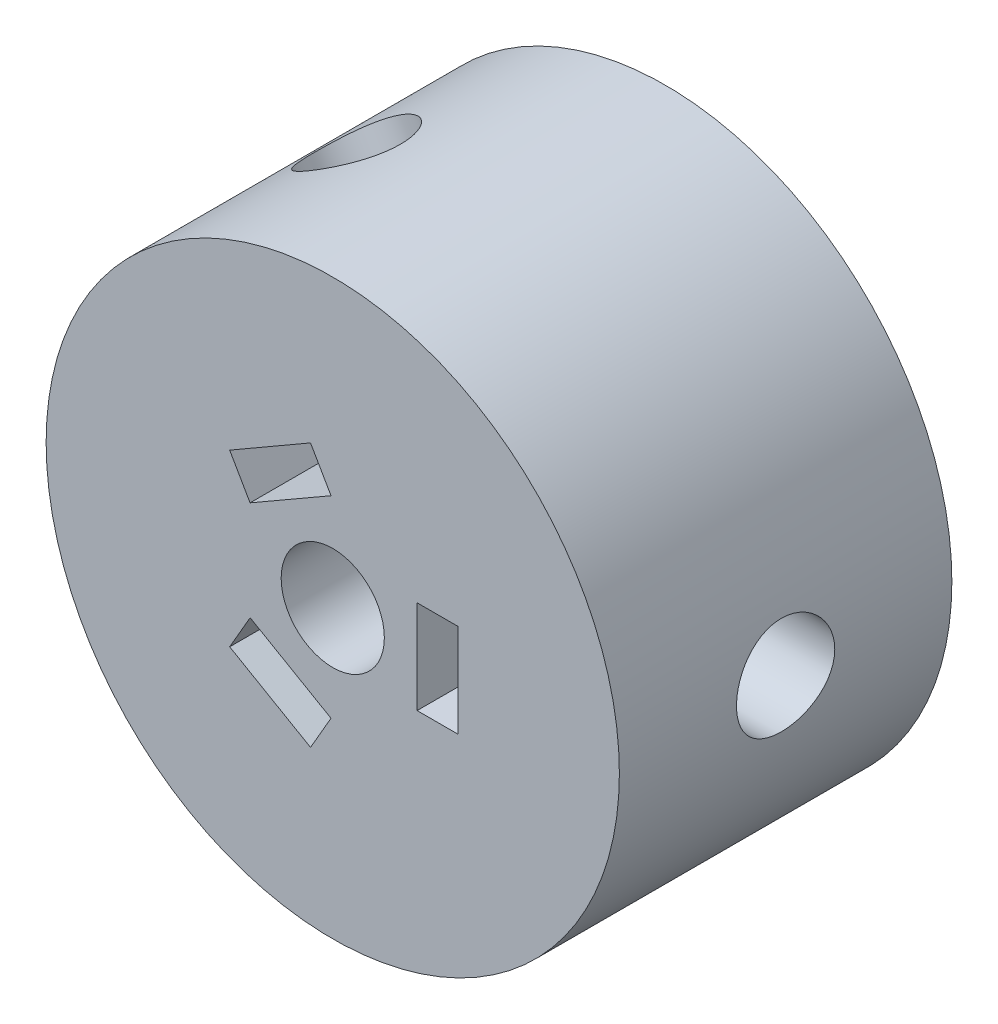
from build123d import *

# Parameters (mm, degrees)
SKETCH1_R           = 17.5
SKETCH1_R_2         = 3.15
BOSS_EXTRUDE1_DEPTH = 40.3
CUT_EXTRUDE1_DEPTH  = 23
CUT_EXTRUDE4_REACH  = 43.405
SKETCH8_R           = 1.65
CUT_EXTRUDE5_REACH  = 43.405
SKETCH10_R          = 1.65
SKETCH12_R          = 3
CUT_EXTRUDE6_DEPTH  = 5.35
SKETCH15_R          = 3
CUT_EXTRUDE8_DEPTH  = 5.35
CUT_EXTRUDE9_REACH  = 43.405
SKETCH17_R          = 1.65
CUT_EXTRUDE10_REACH = 43.405
SKETCH18_R          = 1.65
SKETCH19_R          = 3
CUT_EXTRUDE11_DEPTH = 5.35
CUT_EXTRUDE12_REACH = 37
SKETCH20_R          = 1.65
CUT_EXTRUDE13_REACH = 37
SKETCH21_R          = 1.65
SKETCH22_R          = 17.5
CUT_EXTRUDE14_DEPTH = 10
SKETCH23_R          = 17.5
CUT_EXTRUDE15_DEPTH = 10


with BuildPart() as part:
    # Sketch1 → Boss-Extrude1 (new body)
    with BuildSketch(Plane.XY):
        Circle(SKETCH1_R)
        Circle(SKETCH1_R_2, mode=Mode.SUBTRACT)
    extrude(amount=BOSS_EXTRUDE1_DEPTH)

    # Sketch2 → Cut-Extrude1 (cut)
    with BuildSketch(Plane.XY.offset(40.3)):
        Polygon((7.65, 0), (7.65, 2.85), (5.15, 2.85), (5.15, -2.85), (7.65, -2.85), align=None)
        Polygon((-3.825, -6.625094339), (-1.356827599, -8.050094339), (-0.106827599, -5.885030829), (-5.043172401, -3.035030829), (-6.293172401, -5.200094339), align=None)
        Polygon((-3.825, 6.625094339), (-6.293172401, 5.200094339), (-5.048242412, 3.035349353), (-0.105426694, 5.882604512), (-1.356827546, 8.050094369), align=None)
    extrude(amount=-CUT_EXTRUDE1_DEPTH, mode=Mode.SUBTRACT)

    # Sketch8 → Cut-Extrude4 (cut, up to next)
    with BuildSketch(Plane(origin=(-8.75, -15.155444566, 0), x_dir=(0, 0, -1), z_dir=(-0.5, -0.866025404, 0)), mode=Mode.PRIVATE) as cut_extrude4_sk1:
        with Locations((-20.15, 0)):
            Circle(SKETCH8_R)
    cut_extrude4_tool1 = extrude(cut_extrude4_sk1.sketch, amount=-CUT_EXTRUDE4_REACH, mode=Mode.PRIVATE) & part.part
    add(cut_extrude4_tool1.solids().sort_by_distance((-8.75, -15.155445, 20.15))[0], mode=Mode.SUBTRACT)

    # Sketch10 → Cut-Extrude5 (cut, up to next)
    with BuildSketch(Plane(origin=(-8.75, -15.155444566, 0), x_dir=(0, 0, -1), z_dir=(-0.5, -0.866025404, 0)), mode=Mode.PRIVATE) as cut_extrude5_sk1:
        with Locations((-20.15, 0)):
            Circle(SKETCH10_R)
    cut_extrude5_tool1 = extrude(cut_extrude5_sk1.sketch, amount=-CUT_EXTRUDE5_REACH, mode=Mode.PRIVATE) & part.part
    add(cut_extrude5_tool1.solids().sort_by_distance((-8.75, -15.155445, 20.15))[0], mode=Mode.SUBTRACT)

    # Sketch12 → Cut-Extrude6 (cut)
    with BuildSketch(Plane(origin=(-8.75, -15.155444566, 0), x_dir=(0, 0, -1), z_dir=(-0.5, -0.866025404, 0))):
        with Locations((-20.15, 0)):
            Circle(SKETCH12_R)
    extrude(amount=-CUT_EXTRUDE6_DEPTH, mode=Mode.SUBTRACT)

    # Sketch15 → Cut-Extrude8 (cut)
    with BuildSketch(Plane(origin=(-8.75, 15.155444566, 0), x_dir=(0, 0, -1), z_dir=(-0.5, 0.866025404, 0))):
        with Locations((-20.15, 0)):
            Circle(SKETCH15_R)
    extrude(amount=-CUT_EXTRUDE8_DEPTH, mode=Mode.SUBTRACT)

    # Sketch17 → Cut-Extrude9 (cut, up to next)
    with BuildSketch(Plane(origin=(-8.75, 15.155444566, 0), x_dir=(0, 0, -1), z_dir=(-0.5, 0.866025404, 0)), mode=Mode.PRIVATE) as cut_extrude9_sk1:
        with Locations((-20.15, 0)):
            Circle(SKETCH17_R)
    cut_extrude9_tool1 = extrude(cut_extrude9_sk1.sketch, amount=-CUT_EXTRUDE9_REACH, mode=Mode.PRIVATE) & part.part
    add(cut_extrude9_tool1.solids().sort_by_distance((-8.75, 15.155445, 20.15))[0], mode=Mode.SUBTRACT)

    # Sketch18 → Cut-Extrude10 (cut, up to next)
    with BuildSketch(Plane(origin=(-8.75, 15.155444566, 0), x_dir=(0, 0, -1), z_dir=(-0.5, 0.866025404, 0)), mode=Mode.PRIVATE) as cut_extrude10_sk1:
        with Locations((-20.15, 0)):
            Circle(SKETCH18_R)
    cut_extrude10_tool1 = extrude(cut_extrude10_sk1.sketch, amount=-CUT_EXTRUDE10_REACH, mode=Mode.PRIVATE) & part.part
    add(cut_extrude10_tool1.solids().sort_by_distance((-8.75, 15.155445, 20.15))[0], mode=Mode.SUBTRACT)

    # Sketch19 → Cut-Extrude11 (cut)
    with BuildSketch(Plane(origin=(17.5, 0, 0), x_dir=(0, 0, -1), z_dir=(1, 0, 0))):
        with Locations((-20.15, 0)):
            Circle(SKETCH19_R)
    extrude(amount=-CUT_EXTRUDE11_DEPTH, mode=Mode.SUBTRACT)

    # Sketch20 → Cut-Extrude12 (cut, up to next)
    with BuildSketch(Plane(origin=(17.5, 0, 0), x_dir=(0, 0, -1), z_dir=(1, 0, 0)), mode=Mode.PRIVATE) as cut_extrude12_sk1:
        with Locations((-20.15, 0)):
            Circle(SKETCH20_R)
    cut_extrude12_tool1 = extrude(cut_extrude12_sk1.sketch, amount=-CUT_EXTRUDE12_REACH, mode=Mode.PRIVATE) & part.part
    add(cut_extrude12_tool1.solids().sort_by_distance((17.5, 0, 20.15))[0], mode=Mode.SUBTRACT)

    # Sketch21 → Cut-Extrude13 (cut, up to next)
    with BuildSketch(Plane(origin=(17.5, 0, 0), x_dir=(0, 0, -1), z_dir=(1, 0, 0)), mode=Mode.PRIVATE) as cut_extrude13_sk1:
        with Locations((-20.15, 0)):
            Circle(SKETCH21_R)
    cut_extrude13_tool1 = extrude(cut_extrude13_sk1.sketch, amount=-CUT_EXTRUDE13_REACH, mode=Mode.PRIVATE) & part.part
    add(cut_extrude13_tool1.solids().sort_by_distance((17.5, 0, 20.15))[0], mode=Mode.SUBTRACT)

    # Sketch22 → Cut-Extrude14 (cut)
    with BuildSketch(Plane(origin=(0, 0, 0), x_dir=(-1, 0, 0), z_dir=(0, 0, -1))):
        Circle(SKETCH22_R)
    extrude(amount=-CUT_EXTRUDE14_DEPTH, mode=Mode.SUBTRACT)

    # Sketch23 → Cut-Extrude15 (cut)
    with BuildSketch(Plane.XY.offset(40.3)):
        Circle(SKETCH23_R)
    extrude(amount=-CUT_EXTRUDE15_DEPTH, mode=Mode.SUBTRACT)


solid = part.part
